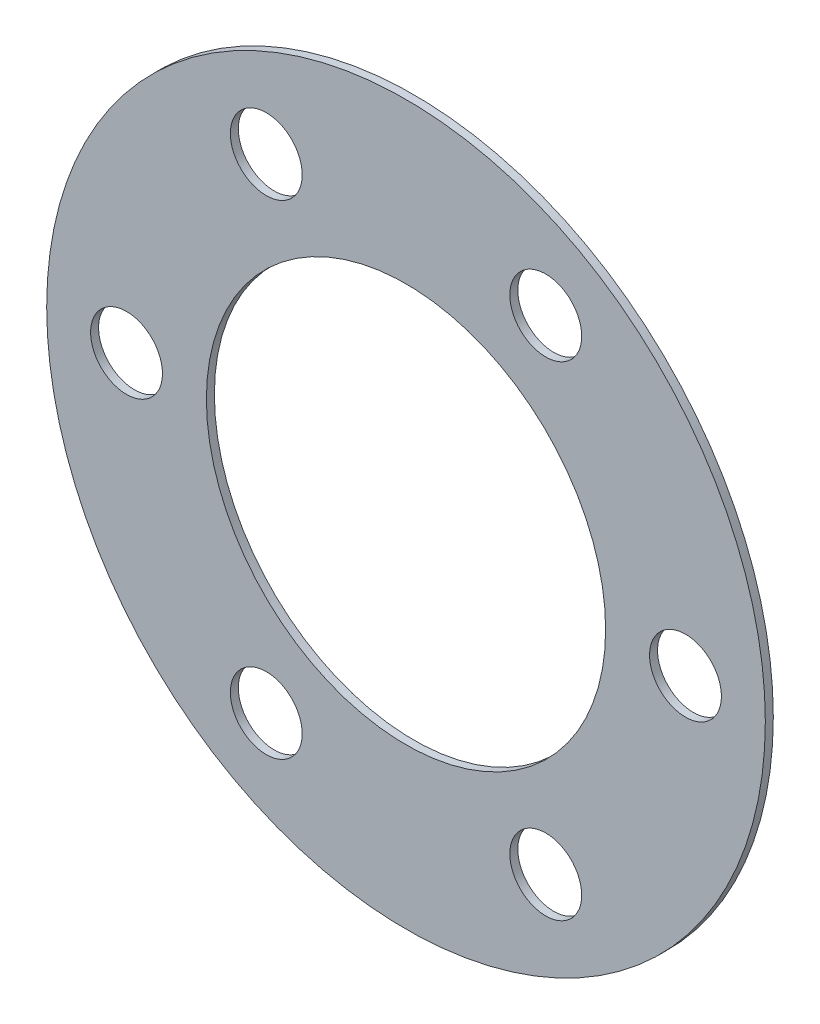
from build123d import *

# Parameters (mm, degrees)
SKICA2_R                = 45
SKICA2_R_2              = 25
SKICA2_R_3              = 4.5
P_IDAT_VYSUNUT_M1_DEPTH = 1


with BuildPart() as part:
    # Skica2 → Přidat vysunutím1 (new body)
    with BuildSketch(Plane.XY):
        Circle(SKICA2_R)
        Circle(SKICA2_R_2, mode=Mode.SUBTRACT)
        with Locations((17.5, 30.310889132)):
            Circle(SKICA2_R_3, mode=Mode.SUBTRACT)
        with Locations((35, 0)):
            Circle(SKICA2_R_3, mode=Mode.SUBTRACT)
        with Locations((17.5, -30.310889132)):
            Circle(SKICA2_R_3, mode=Mode.SUBTRACT)
        with Locations((-17.5, -30.310889132)):
            Circle(SKICA2_R_3, mode=Mode.SUBTRACT)
        with Locations((-35, 0)):
            Circle(SKICA2_R_3, mode=Mode.SUBTRACT)
        with Locations((-17.5, 30.310889132)):
            Circle(SKICA2_R_3, mode=Mode.SUBTRACT)
    extrude(amount=P_IDAT_VYSUNUT_M1_DEPTH)


solid = part.part
